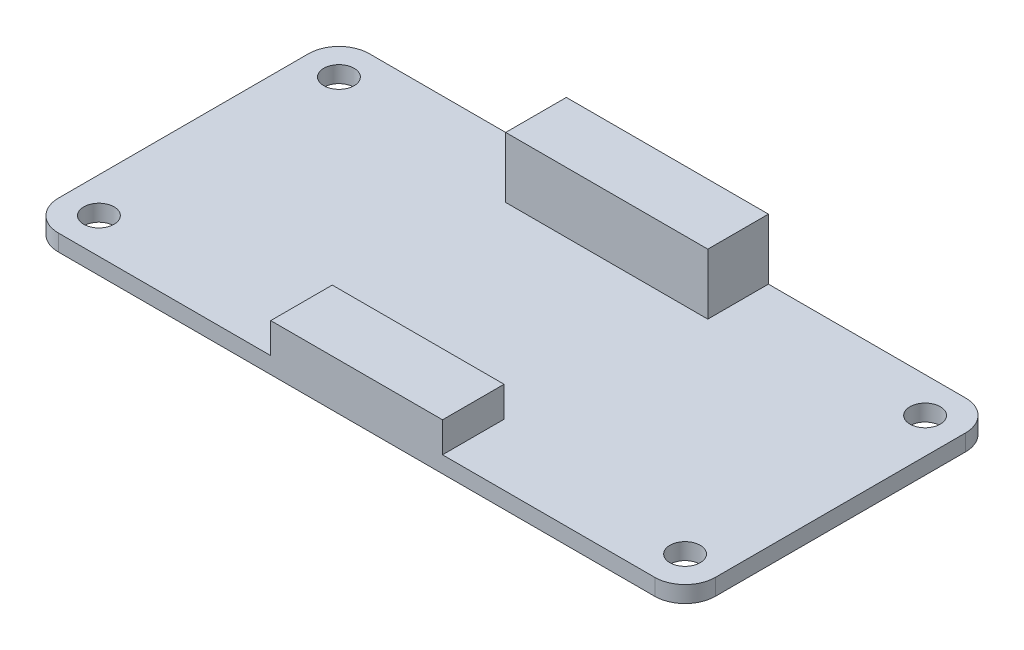
from build123d import *

# Parameters (mm, degrees)
EXTRUDE_1_DEPTH     = 1.63
SKETCH_2_R          = 1.5
CUT_EXTRUDE_1_DEPTH = 2.63
SKETCH_8_W          = 51
SKETCH_8_H          = 5
EXTRUDE_6_DEPTH     = 3.68
SKETCH_9_W          = 17
SKETCH_9_H          = 6.090540171
EXTRUDE_7_DEPTH     = 3
SKETCH_10_W         = 20
SKETCH_10_H         = 6
EXTRUDE_8_DEPTH     = 6


with BuildPart() as part:
    # 草图1 → 凸台-拉伸1 (new body)
    with BuildSketch(Plane(origin=(0, 0, 0), x_dir=(1, 0, 0), z_dir=(0, 1, 0))):
        with BuildLine():
            Line((-29.5, 15.375), (29.5, 15.375))
            ThreePointArc((29.5, 15.375), (31.621320344, 14.496320344), (32.5, 12.375))
            Line((32.5, 12.375), (32.5, -12.375))
            ThreePointArc((32.5, -12.375), (31.621320344, -14.496320344), (29.5, -15.375))
            Line((29.5, -15.375), (-29.5, -15.375))
            ThreePointArc((-29.5, -15.375), (-31.621320344, -14.496320344), (-32.5, -12.375))
            Line((-32.5, -12.375), (-32.5, 12.375))
            ThreePointArc((-32.5, 12.375), (-31.621320344, 14.496320344), (-29.5, 15.375))
        make_face()
    extrude(amount=EXTRUDE_1_DEPTH)

    # 草图2 → 切除-拉伸1 (cut, through all)
    with BuildSketch(Plane(origin=(0, 1.63, 0), x_dir=(1, 0, 0), z_dir=(0, 1, 0))):
        with Locations(Location((-29, 11.875, 0), (0, 0, 270))):  # turned: the seam where the file's is
            Circle(SKETCH_2_R)
        with Locations(Location((-29, -11.875, 0), (0, 0, 270))):  # turned: the seam where the file's is
            Circle(SKETCH_2_R)
        with Locations(Location((29, -11.875, 0), (0, 0, 270))):  # turned: the seam where the file's is
            Circle(SKETCH_2_R)
        with Locations(Location((29, 11.875, 0), (0, 0, 270))):  # turned: the seam where the file's is
            Circle(SKETCH_2_R)
    extrude(amount=-CUT_EXTRUDE_1_DEPTH, mode=Mode.SUBTRACT)

    # 草图8 → 凸台-拉伸6 (add)
    with BuildSketch(Plane.XZ):
        with Locations((-0.2, -11.235)):
            Rectangle(SKETCH_8_W, SKETCH_8_H)
    extrude(amount=EXTRUDE_6_DEPTH)

    # 草图9 → 凸台-拉伸7 (add)
    with BuildSketch(Plane(origin=(0, 1.63, 0), x_dir=(1, 0, 0), z_dir=(0, 1, 0))):
        with Locations((0, -12.329729915)):
            Rectangle(SKETCH_9_W, SKETCH_9_H)
    extrude(amount=EXTRUDE_7_DEPTH)

    # 草图10 → 凸台-拉伸8 (add)
    with BuildSketch(Plane(origin=(0, 1.63, 0), x_dir=(1, 0, 0), z_dir=(0, 1, 0))):
        with Locations((0, 12.375)):
            Rectangle(SKETCH_10_W, SKETCH_10_H)
    extrude(amount=EXTRUDE_8_DEPTH)


solid = part.part
